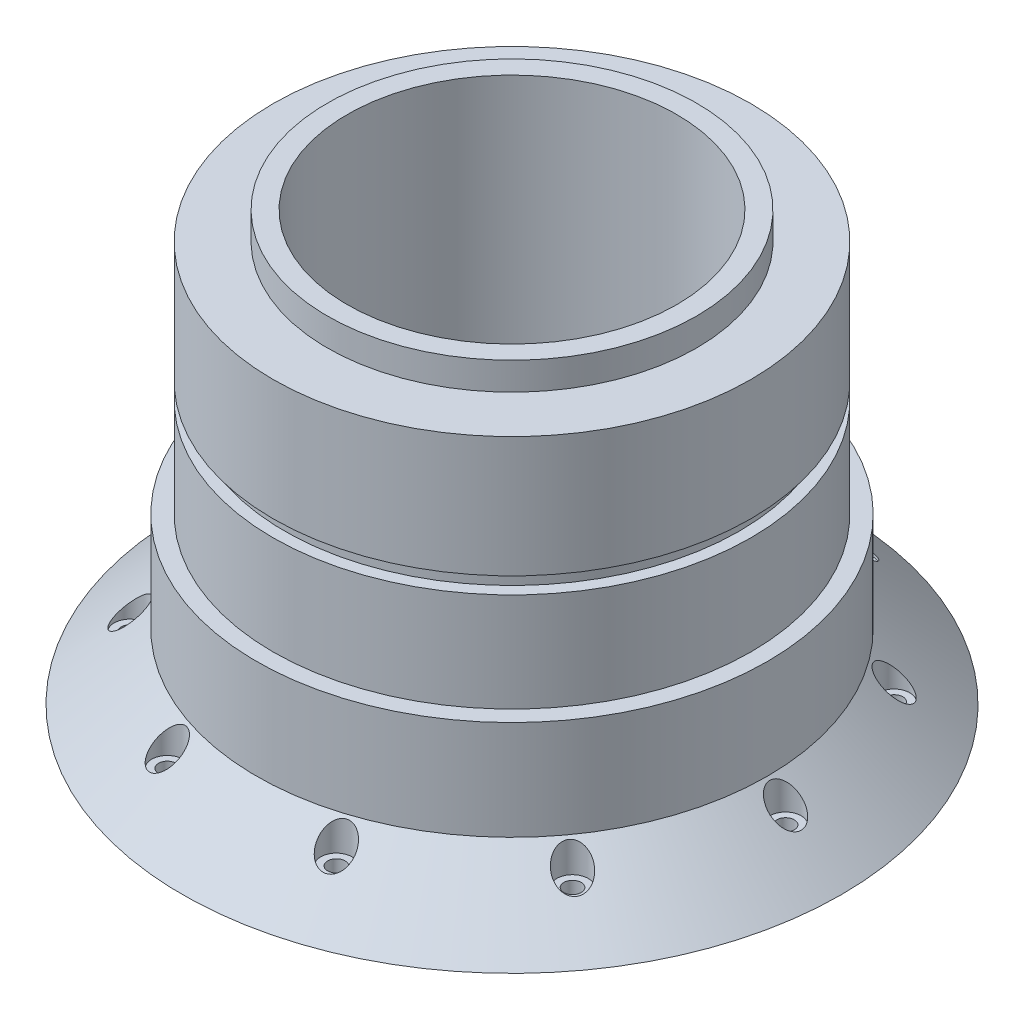
from build123d import *

# Parameters (mm, degrees)
HOLE_WIZARD_M5_4_D           = 5.3
HOLE_WIZARD_M5_4_CBORE_D     = 9.5
HOLE_WIZARD_M5_4_CBORE_DEPTH = 10


with BuildPart() as part:
    # 스케치1 → 회전1 (revolve)
    with BuildSketch(Plane.XY):
        Polygon((-99.991995848, 36.774389527), (-49.991995848, 36.774389527), (-49.991995848, 166.774389527), (-55.991995848, 166.774389527), (-55.991995848, 158.374389527), (-72.491995848, 158.374389527), (-72.491995848, 121.774389527), (-68.991995848, 121.774389527), (-68.991995848, 116.774389527), (-72.491995848, 116.774389527), (-72.491995848, 86.774389527), (-77.490912172, 86.774389527), (-77.490912172, 69.169208271), (-77.490912172, 56.61629552), align=None)
    revolve(axis=Axis((0, 0, 0), (0, 1, 0)))

    # M5 치즈머리 홈붙이 머리용 카운터보어4 (through all)
    with Locations(Plane(origin=(0, 56.61629552, 0), x_dir=(-1, 0, 0), z_dir=(0, 1, 0))):
        with Locations((-83, 0), (-67.148410533, -48.78617594), (-25.648410533, -78.937690852), (25.648410533, -78.937690852), (67.148410533, -48.78617594), (83, 0), (67.148410533, 48.78617594), (-67.148410533, 48.78617594), (-25.648410533, 78.937690852), (25.648410533, 78.937690852)):
            CounterBoreHole(HOLE_WIZARD_M5_4_D / 2, HOLE_WIZARD_M5_4_CBORE_D / 2, HOLE_WIZARD_M5_4_CBORE_DEPTH)


solid = part.part
